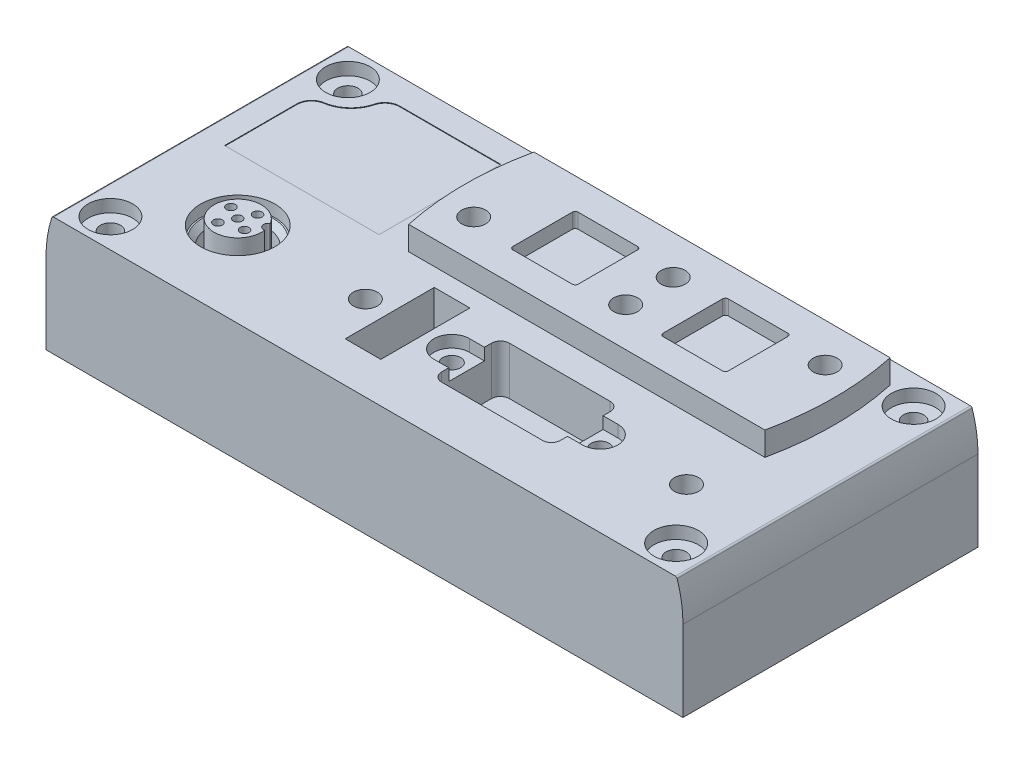
from build123d import *

# Parameters (mm, degrees)
BOSS_EXTRUDE1_DEPTH      = 24.85
BOSS_EXTRUDE1_DEPTH_BACK = 24.85
SKETCH7_R                = 0.75
BOSS_EXTRUDE2_DEPTH      = 8.6
BOSS_EXTRUDE3_DEPTH      = 4
SKETCH9_R                = 2.025
CUT_EXTRUDE1_DEPTH       = 6.6
SKETCH10_R               = 2.025
CUT_EXTRUDE2_DEPTH       = 6.6
SKETCH11_R               = 2.025
CUT_EXTRUDE3_DEPTH       = 6.6
SKETCH12_R               = 2.025
CUT_EXTRUDE4_DEPTH       = 6.6
SKETCH13_R               = 2.025
CUT_EXTRUDE5_DEPTH       = 6.6
SKETCH14_R               = 2.025
CUT_EXTRUDE6_DEPTH       = 6.6
CUT_EXTRUDE7_DEPTH       = 2
CUT_EXTRUDE8_DEPTH       = 8.1
SKETCH17_R               = 1.5
CUT_EXTRUDE9_DEPTH       = 5
SKETCH18_R               = 1.5
CUT_EXTRUDE10_DEPTH      = 5
CUT_EXTRUDE11_DEPTH      = 2.5
CUT_EXTRUDE12_DEPTH      = 2.5
CUT_EXTRUDE13_DEPTH      = 6
CUT_EXTRUDE14_DEPTH      = 10
CUT_EXTRUDE15_DEPTH      = 15
CUT_EXTRUDE16_START      = -0.1
CUT_EXTRUDE16_DEPTH      = 0.1


with BuildPart() as part:
    # Sketch1 → Boss-Extrude1 (new, two sides: drawn at the far end of the back side and taken through both)
    with BuildSketch(Plane.XY.offset(-BOSS_EXTRUDE1_DEPTH_BACK)):
        with BuildLine():
            Line((-53.65, 13.6), (-53.65, 0))
            Line((-53.65, 0), (53.65, 0))
            Line((53.65, 0), (53.65, 13.6))
            ThreePointArc((53.65, 13.6), (53.402733193, 16.735208348), (52.667046861, 19.792893401))
            ThreePointArc((52.667046861, 19.792893401), (52.558046626, 19.94276328), (52.381791158, 20))
            Line((52.381791158, 20), (-52.381791158, 20))
            ThreePointArc((-52.381791158, 20), (-52.558046626, 19.94276328), (-52.667046861, 19.792893401))
            ThreePointArc((-52.667046861, 19.792893401), (-53.402733193, 16.735208348), (-53.65, 13.6))
        make_face()
    extrude(amount=BOSS_EXTRUDE1_DEPTH + BOSS_EXTRUDE1_DEPTH_BACK)

    # Sketch2 → Cut-Revolve1 (revolve, cut)
    with BuildSketch(Plane.XY.offset(20)):
        Polygon((47.65, 20), (51.4, 20), (51.4, 17.9), (49.35, 17.9), (49.35, 12.773205081), (49.05, 12.6), (49.05, 12), (49.35, 12), (49.35, 0), (47.65, 0), align=None)
    revolve(axis=Axis((47.65, 0, 20), (0, 1, 0)), mode=Mode.SUBTRACT)

    # Sketch3 → Cut-Revolve2 (revolve, cut)
    with BuildSketch(Plane.XY.offset(-20)):
        Polygon((47.65, 20), (51.4, 20), (51.4, 17.9), (49.35, 17.9), (49.35, 12.773205081), (49.05, 12.6), (49.05, 12), (49.35, 12), (49.35, 0), (47.65, 0), align=None)
    revolve(axis=Axis((47.65, 0, -20), (0, 1, 0)), mode=Mode.SUBTRACT)

    # Sketch4 → Cut-Revolve3 (revolve, cut)
    with BuildSketch(Plane.XY.offset(-20)):
        Polygon((-47.65, 20), (-43.9, 20), (-43.9, 17.9), (-45.95, 17.9), (-45.95, 12.773205081), (-46.25, 12.6), (-46.25, 12), (-45.95, 12), (-45.95, 0), (-47.65, 0), align=None)
    revolve(axis=Axis((-47.65, 0, -20), (0, 1, 0)), mode=Mode.SUBTRACT)

    # Sketch5 → Cut-Revolve4 (revolve, cut)
    with BuildSketch(Plane.XY.offset(20)):
        Polygon((-47.65, 20), (-43.9, 20), (-43.9, 17.9), (-45.95, 17.9), (-45.95, 12.773205081), (-46.25, 12.6), (-46.25, 12), (-45.95, 12), (-45.95, 0), (-47.65, 0), align=None)
    revolve(axis=Axis((-47.65, 0, 20), (0, 1, 0)), mode=Mode.SUBTRACT)

    # Sketch6 → Cut-Revolve5 (revolve, cut)
    with BuildSketch(Plane.XY.offset(10.55)):
        Polygon((-35.65, 12.4), (-41.65, 12.4), (-40.703, 13.347), (-40.703, 17.053), (-41.65, 18), (-41.9, 18), (-41.9, 20), (-35.65, 20), align=None)
    revolve(axis=Axis((-35.65, 20, 10.55), (0, -1, 0)), mode=Mode.SUBTRACT)

    # Sketch7 → Boss-Extrude2 (add)
    with BuildSketch(Plane(origin=(0, 21, 0), x_dir=(1, 0, 0), z_dir=(0, 1, 0))):
        with BuildLine():
            ThreePointArc((-32.177508181, -8.564603172), (-39.432074302, -11.852272618), (-31.691306764, -9.976634614))
            ThreePointArc((-31.691306764, -9.976634614), (-32.577064629, -9.491903498), (-32.177508181, -8.564603172))
        make_face()
        with Locations((-33.403014884, -11.645927867)):
            Circle(SKETCH7_R, mode=Mode.SUBTRACT)
        with Locations((-34.554072133, -8.303014884)):
            Circle(SKETCH7_R, mode=Mode.SUBTRACT)
        with Locations((-35.65, -10.55)):
            Circle(SKETCH7_R, mode=Mode.SUBTRACT)
        with Locations((-36.745927867, -12.796985116)):
            Circle(SKETCH7_R, mode=Mode.SUBTRACT)
        with Locations((-37.896985116, -9.454072133)):
            Circle(SKETCH7_R, mode=Mode.SUBTRACT)
    extrude(amount=-BOSS_EXTRUDE2_DEPTH)

    # Sketch8 → Boss-Extrude3 (add)
    with BuildSketch(Plane(origin=(0, 24, 0), x_dir=(1, 0, 0), z_dir=(0, 1, 0))):
        with BuildLine():
            Line((-17.4, 0), (42.6, 0))
            ThreePointArc((42.6, 0), (43.725696936, 10.55), (42.6, 21.1))
            Line((42.6, 21.1), (-17.4, 21.1))
            ThreePointArc((-17.4, 21.1), (-18.525696936, 10.55), (-17.4, 0))
        make_face()
    extrude(amount=-BOSS_EXTRUDE3_DEPTH)

    # Sketch9 → Cut-Extrude1 (cut)
    with BuildSketch(Plane(origin=(0, 24, 0), x_dir=(1, 0, 0), z_dir=(0, 1, 0))):
        with Locations((-13, 6.55)):
            Circle(SKETCH9_R)
    extrude(amount=-CUT_EXTRUDE1_DEPTH, mode=Mode.SUBTRACT)

    # Sketch10 → Cut-Extrude2 (cut)
    with BuildSketch(Plane(origin=(0, 24, 0), x_dir=(1, 0, 0), z_dir=(0, 1, 0))):
        with Locations((12.6, 14.55)):
            Circle(SKETCH10_R)
    extrude(amount=-CUT_EXTRUDE2_DEPTH, mode=Mode.SUBTRACT)

    # Sketch11 → Cut-Extrude3 (cut)
    with BuildSketch(Plane(origin=(0, 24, 0), x_dir=(1, 0, 0), z_dir=(0, 1, 0))):
        with Locations((12.6, 6.55)):
            Circle(SKETCH11_R)
    extrude(amount=-CUT_EXTRUDE3_DEPTH, mode=Mode.SUBTRACT)

    # Sketch12 → Cut-Extrude4 (cut)
    with BuildSketch(Plane(origin=(0, 24, 0), x_dir=(1, 0, 0), z_dir=(0, 1, 0))):
        with Locations((38.2, 14.55)):
            Circle(SKETCH12_R)
    extrude(amount=-CUT_EXTRUDE4_DEPTH, mode=Mode.SUBTRACT)

    # Sketch13 → Cut-Extrude5 (cut)
    with BuildSketch(Plane(origin=(0, 20, 0), x_dir=(1, 0, 0), z_dir=(0, 1, 0))):
        with Locations((-14.15, -10.55)):
            Circle(SKETCH13_R)
    extrude(amount=-CUT_EXTRUDE5_DEPTH, mode=Mode.SUBTRACT)

    # Sketch14 → Cut-Extrude6 (cut)
    with BuildSketch(Plane(origin=(0, 20, 0), x_dir=(1, 0, 0), z_dir=(0, 1, 0))):
        with Locations((39.95, -10.55)):
            Circle(SKETCH14_R)
    extrude(amount=-CUT_EXTRUDE6_DEPTH, mode=Mode.SUBTRACT)

    # Sketch15 → Cut-Extrude7 (cut)
    with BuildSketch(Plane(origin=(0, 20, 0), x_dir=(1, 0, 0), z_dir=(0, 1, 0))):
        with BuildLine():
            Line((0.4, -13.55), (2.9, -13.55))
            Line((2.9, -13.55), (2.9, -14.55))
            ThreePointArc((2.9, -14.55), (3.192893219, -15.257106781), (3.9, -15.55))
            Line((3.9, -15.55), (21.9, -15.55))
            ThreePointArc((21.9, -15.55), (22.607106781, -15.257106781), (22.9, -14.55))
            Line((22.9, -14.55), (22.9, -13.55))
            Line((22.9, -13.55), (25.4, -13.55))
            ThreePointArc((25.4, -13.55), (28.4, -10.55), (25.4, -7.55))
            Line((25.4, -7.55), (22.9, -7.55))
            Line((22.9, -7.55), (22.9, -6.55))
            ThreePointArc((22.9, -6.55), (22.607106781, -5.842893219), (21.9, -5.55))
            Line((21.9, -5.55), (3.9, -5.55))
            ThreePointArc((3.9, -5.55), (3.192893219, -5.842893219), (2.9, -6.55))
            Line((2.9, -6.55), (2.9, -7.55))
            Line((2.9, -7.55), (0.4, -7.55))
            ThreePointArc((0.4, -7.55), (-2.6, -10.55), (0.4, -13.55))
        make_face()
    extrude(amount=-CUT_EXTRUDE7_DEPTH, mode=Mode.SUBTRACT)

    # Sketch16 → Cut-Extrude8 (cut)
    with BuildSketch(Plane(origin=(0, 20, 0), x_dir=(1, 0, 0), z_dir=(0, 1, 0))):
        with BuildLine():
            Line((2.9, -6.35), (2.9, -14.75))
            ThreePointArc((2.9, -14.75), (3.339339828, -15.810660172), (4.4, -16.25))
            Line((4.4, -16.25), (21.4, -16.25))
            ThreePointArc((21.4, -16.25), (22.460660172, -15.810660172), (22.9, -14.75))
            Line((22.9, -14.75), (22.9, -6.35))
            ThreePointArc((22.9, -6.35), (22.460660172, -5.289339828), (21.4, -4.85))
            Line((21.4, -4.85), (4.4, -4.85))
            ThreePointArc((4.4, -4.85), (3.339339828, -5.289339828), (2.9, -6.35))
        make_face()
    extrude(amount=-CUT_EXTRUDE8_DEPTH, mode=Mode.SUBTRACT)

    # Sketch17 → Cut-Extrude9 (cut)
    with BuildSketch(Plane(origin=(0, 20, 0), x_dir=(1, 0, 0), z_dir=(0, 1, 0))):
        with Locations((25.4, -10.55)):
            Circle(SKETCH17_R)
    extrude(amount=-CUT_EXTRUDE9_DEPTH, mode=Mode.SUBTRACT)

    # Sketch18 → Cut-Extrude10 (cut)
    with BuildSketch(Plane(origin=(0, 20, 0), x_dir=(1, 0, 0), z_dir=(0, 1, 0))):
        with Locations((0.4, -10.55)):
            Circle(SKETCH18_R)
    extrude(amount=-CUT_EXTRUDE10_DEPTH, mode=Mode.SUBTRACT)

    # Sketch19 → Cut-Extrude11 (cut)
    with BuildSketch(Plane(origin=(0, 24, 0), x_dir=(1, 0, 0), z_dir=(0, 1, 0))):
        with BuildLine():
            Line((-5.4, 15.55), (-5.4, 5.55))
            ThreePointArc((-5.4, 5.55), (-5.253553391, 5.196446609), (-4.9, 5.05))
            Line((-4.9, 5.05), (5.1, 5.05))
            ThreePointArc((5.1, 5.05), (5.453553391, 5.196446609), (5.6, 5.55))
            Line((5.6, 5.55), (5.6, 15.55))
            ThreePointArc((5.6, 15.55), (5.453553391, 15.903553391), (5.1, 16.05))
            Line((5.1, 16.05), (-4.9, 16.05))
            ThreePointArc((-4.9, 16.05), (-5.253553391, 15.903553391), (-5.4, 15.55))
        make_face()
    extrude(amount=-CUT_EXTRUDE11_DEPTH, mode=Mode.SUBTRACT)

    # Sketch20 → Cut-Extrude12 (cut)
    with BuildSketch(Plane(origin=(0, 24, 0), x_dir=(1, 0, 0), z_dir=(0, 1, 0))):
        with BuildLine():
            Line((19.9, 15.55), (19.9, 5.55))
            ThreePointArc((19.9, 5.55), (20.046446609, 5.196446609), (20.4, 5.05))
            Line((20.4, 5.05), (30.4, 5.05))
            ThreePointArc((30.4, 5.05), (30.753553391, 5.196446609), (30.9, 5.55))
            Line((30.9, 5.55), (30.9, 15.55))
            ThreePointArc((30.9, 15.55), (30.753553391, 15.903553391), (30.4, 16.05))
            Line((30.4, 16.05), (20.4, 16.05))
            ThreePointArc((20.4, 16.05), (20.046446609, 15.903553391), (19.9, 15.55))
        make_face()
    extrude(amount=-CUT_EXTRUDE12_DEPTH, mode=Mode.SUBTRACT)

    # Sketch21 → Cut-Extrude13 (cut)
    with BuildSketch(Plane(origin=(-10.05, 0, 0), x_dir=(0, 0, -1), z_dir=(1, 0, 0))):
        Polygon((-18.05, 11.9), (-11.05, 11.9), (-11.05, 12.9), (-10.05, 12.9), (-10.05, 11.9), (-3.05, 11.9), (-3.05, 20), (-18.05, 20), align=None)
    extrude(amount=CUT_EXTRUDE13_DEPTH, mode=Mode.SUBTRACT)

    # Sketch22 → Cut-Extrude14 (cut)
    with BuildSketch(Plane(origin=(0, 0, 0), x_dir=(1, 0, 0), z_dir=(0, 1, 0))):
        with BuildLine():
            Line((-48.4, 12.151203914), (-48.4, -12.151203914))
            ThreePointArc((-48.4, -12.151203914), (-47.79906628, -13.773402604), (-46.286322418, -14.612602183))
            ThreePointArc((-46.286322418, -14.612602183), (-43.456956945, -15.955525197), (-41.833947517, -18.63406801))
            ThreePointArc((-41.833947517, -18.63406801), (-40.94758788, -19.979013629), (-39.423420787, -20.5))
            Line((-39.423420787, -20.5), (40.207977783, -20.5))
            ThreePointArc((40.207977783, -20.5), (41.419271502, -20.057764768), (42.060696328, -18.939114391))
            ThreePointArc((42.060696328, -18.939114391), (43.712891101, -15.670049726), (46.913111931, -13.888163649))
            ThreePointArc((46.913111931, -13.888163649), (47.981754157, -13.231956241), (48.4, -12.049723275))
            Line((48.4, -12.049723275), (48.4, 12.049723275))
            ThreePointArc((48.4, 12.049723275), (47.981754157, 13.231956241), (46.913111931, 13.888163649))
            ThreePointArc((46.913111931, 13.888163649), (43.712891101, 15.670049726), (42.060696328, 18.939114391))
            ThreePointArc((42.060696328, 18.939114391), (41.419271502, 20.057764768), (40.207977783, 20.5))
            Line((40.207977783, 20.5), (-39.423420787, 20.5))
            ThreePointArc((-39.423420787, 20.5), (-40.94758788, 19.979013629), (-41.833947517, 18.63406801))
            ThreePointArc((-41.833947517, 18.63406801), (-43.456956895, 15.955525241), (-46.286322286, 14.612602203))
            ThreePointArc((-46.286322286, 14.612602203), (-47.799066237, 13.773402654), (-48.4, 12.151203914))
        make_face()
    extrude(amount=CUT_EXTRUDE14_DEPTH, mode=Mode.SUBTRACT)

    # Sketch23 → Cut-Extrude15 (cut)
    with BuildSketch(Plane(origin=(0, 0, 0), x_dir=(1, 0, 0), z_dir=(0, 1, 0))):
        with BuildLine():
            Line((-48.4, 12.151203914), (-48.4, 0))
            Line((-48.4, 0), (-22.4, 0))
            Line((-22.4, 0), (-22.4, 20.5))
            Line((-22.4, 20.5), (-39.423420787, 20.5))
            ThreePointArc((-39.423420787, 20.5), (-40.94758788, 19.979013629), (-41.833947517, 18.63406801))
            ThreePointArc((-41.833947517, 18.63406801), (-43.456956895, 15.955525241), (-46.286322286, 14.612602203))
            ThreePointArc((-46.286322286, 14.612602203), (-47.799066237, 13.773402654), (-48.4, 12.151203914))
        make_face()
    extrude(amount=CUT_EXTRUDE15_DEPTH, mode=Mode.SUBTRACT)

    # Sketch24 → Cut-Extrude16 (cut)
    with BuildSketch(Plane(origin=(0, 20, 0), x_dir=(1, 0, 0), z_dir=(0, 1, 0)).offset(CUT_EXTRUDE16_START)):
        with BuildLine():
            Line((-48.4, 12.151203914), (-48.4, 0))
            Line((-48.4, 0), (-22.4, 0))
            Line((-22.4, 0), (-22.4, 20.5))
            Line((-22.4, 20.5), (-39.423420787, 20.5))
            ThreePointArc((-39.423420787, 20.5), (-40.94758788, 19.979013629), (-41.833947517, 18.63406801))
            ThreePointArc((-41.833947517, 18.63406801), (-43.456956895, 15.955525241), (-46.286322286, 14.612602203))
            ThreePointArc((-46.286322286, 14.612602203), (-47.799066237, 13.773402654), (-48.4, 12.151203914))
        make_face()
    extrude(amount=CUT_EXTRUDE16_DEPTH, mode=Mode.SUBTRACT)


solid = part.part
